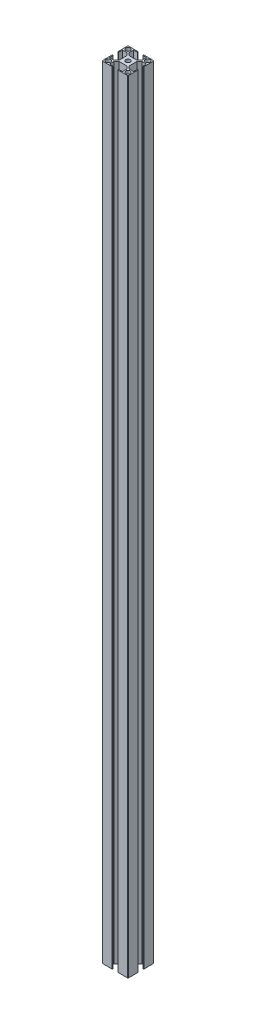
from build123d import *

# Parameters (mm, degrees)
SKETCH1_R           = 3.5
BOSS_EXTRUDE1_DEPTH = 1200
CUT_EXTRUDE1_DEPTH  = 1201


with BuildPart() as part:
    # Sketch1 → Boss-Extrude1 (new body)
    with BuildSketch(Plane(origin=(0, 0, 0), x_dir=(1, 0, 0), z_dir=(0, 1, 0))):
        with BuildLine():
            Line((20, 19), (20, -19))
            ThreePointArc((20, -19), (19.707106781, -19.707106781), (19, -20))
            Line((19, -20), (-19, -20))
            ThreePointArc((-19, -20), (-19.707106781, -19.707106781), (-20, -19))
            Line((-20, -19), (-20, 19))
            ThreePointArc((-20, 19), (-19.707106781, 19.707106781), (-19, 20))
            Line((-19, 20), (19, 20))
            ThreePointArc((19, 20), (19.707106781, 19.707106781), (20, 19))
        make_face()
        with Locations((15.1625, -15.1625)):
            Circle(SKETCH1_R, mode=Mode.SUBTRACT)
        with Locations((-15.1625, -15.1625)):
            Circle(SKETCH1_R, mode=Mode.SUBTRACT)
        with Locations((-15.1625, 15.1625)):
            Circle(SKETCH1_R, mode=Mode.SUBTRACT)
        with Locations((15.1625, 15.1625)):
            Circle(SKETCH1_R, mode=Mode.SUBTRACT)
        Circle(SKETCH1_R, mode=Mode.SUBTRACT)
        Polygon((-10, -18.5), (10, -18.5), (10, -11.825), (5.875, -7.7), (-5.875, -7.7), (-10, -11.825), align=None, mode=Mode.SUBTRACT)
        Polygon((-11.825, -10), (-18.5, -10), (-18.5, 10), (-11.825, 10), (-7.7, 5.875), (-7.7, -5.875), align=None, mode=Mode.SUBTRACT)
        Polygon((-10, 11.825), (-10, 18.5), (10, 18.5), (10, 11.825), (5.875, 7.7), (-5.875, 7.7), align=None, mode=Mode.SUBTRACT)
        Polygon((18.5, -10), (18.5, 10), (11.825, 10), (7.7, 5.875), (7.7, -5.875), (11.825, -10), align=None, mode=Mode.SUBTRACT)
    extrude(amount=BOSS_EXTRUDE1_DEPTH)

    # Sketch2 → Cut-Extrude1 (cut, through all)
    with BuildSketch(Plane(origin=(0, 1200, 0), x_dir=(1, 0, 0), z_dir=(0, 1, 0))):
        with BuildLine():
            Line((-4.65, 20), (-4.65, 19.35))
            ThreePointArc((-4.65, 19.35), (-4.620710678, 19.279289322), (-4.55, 19.25))
            Line((-4.55, 19.25), (-4.25, 19.25))
            ThreePointArc((-4.25, 19.25), (-4.179289322, 19.220710678), (-4.15, 19.15))
            Line((-4.15, 19.15), (-4.15, 18.5))
            Line((-4.15, 18.5), (4.15, 18.5))
            Line((4.15, 18.5), (4.15, 19.15))
            ThreePointArc((4.15, 19.15), (4.179289322, 19.220710678), (4.25, 19.25))
            Line((4.25, 19.25), (4.55, 19.25))
            ThreePointArc((4.55, 19.25), (4.620710678, 19.279289322), (4.65, 19.35))
            Line((4.65, 19.35), (4.65, 20))
            Line((4.65, 20), (-4.65, 20))
        make_face()
        with BuildLine():
            Line((20, 4.65), (19.35, 4.65))
            ThreePointArc((19.35, 4.65), (19.279289322, 4.620710678), (19.25, 4.55))
            Line((19.25, 4.55), (19.25, 4.25))
            ThreePointArc((19.25, 4.25), (19.220710678, 4.179289322), (19.15, 4.15))
            Line((19.15, 4.15), (18.5, 4.15))
            Line((18.5, 4.15), (18.5, -4.15))
            Line((18.5, -4.15), (19.15, -4.15))
            ThreePointArc((19.15, -4.15), (19.220710678, -4.179289322), (19.25, -4.25))
            Line((19.25, -4.25), (19.25, -4.55))
            ThreePointArc((19.25, -4.55), (19.279289322, -4.620710678), (19.35, -4.65))
            Line((19.35, -4.65), (20, -4.65))
            Line((20, -4.65), (20, 4.65))
        make_face()
        with BuildLine():
            Line((4.65, -20), (4.65, -19.35))
            ThreePointArc((4.65, -19.35), (4.620710678, -19.279289322), (4.55, -19.25))
            Line((4.55, -19.25), (4.25, -19.25))
            ThreePointArc((4.25, -19.25), (4.179289322, -19.220710678), (4.15, -19.15))
            Line((4.15, -19.15), (4.15, -18.5))
            Line((4.15, -18.5), (-4.15, -18.5))
            Line((-4.15, -18.5), (-4.15, -19.15))
            ThreePointArc((-4.15, -19.15), (-4.179289322, -19.220710678), (-4.25, -19.25))
            Line((-4.25, -19.25), (-4.55, -19.25))
            ThreePointArc((-4.55, -19.25), (-4.620710678, -19.279289322), (-4.65, -19.35))
            Line((-4.65, -19.35), (-4.65, -20))
            Line((-4.65, -20), (4.65, -20))
        make_face()
        with BuildLine():
            Line((-20, -4.65), (-19.35, -4.65))
            ThreePointArc((-19.35, -4.65), (-19.279289322, -4.620710678), (-19.25, -4.55))
            Line((-19.25, -4.55), (-19.25, -4.25))
            ThreePointArc((-19.25, -4.25), (-19.220710678, -4.179289322), (-19.15, -4.15))
            Line((-19.15, -4.15), (-18.5, -4.15))
            Line((-18.5, -4.15), (-18.5, 4.15))
            Line((-18.5, 4.15), (-19.15, 4.15))
            ThreePointArc((-19.15, 4.15), (-19.220710678, 4.179289322), (-19.25, 4.25))
            Line((-19.25, 4.25), (-19.25, 4.55))
            ThreePointArc((-19.25, 4.55), (-19.279289322, 4.620710678), (-19.35, 4.65))
            Line((-19.35, 4.65), (-20, 4.65))
            Line((-20, 4.65), (-20, -4.65))
        make_face()
    extrude(amount=-CUT_EXTRUDE1_DEPTH, mode=Mode.SUBTRACT)


solid = part.part
